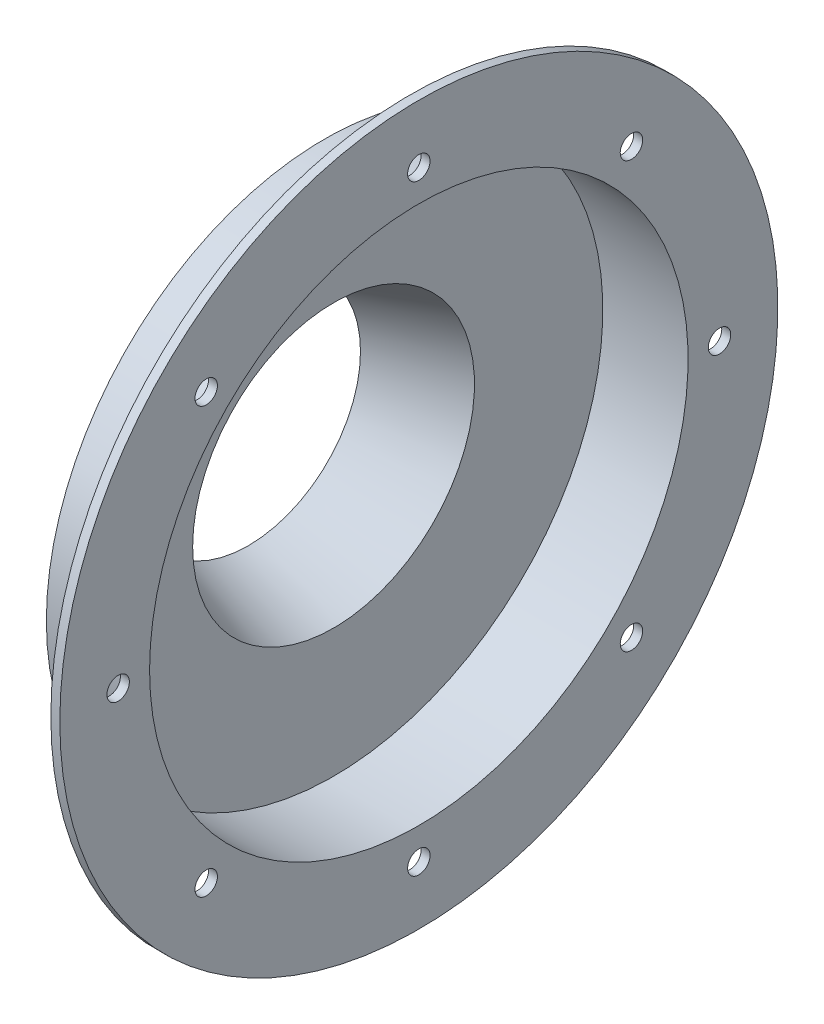
from build123d import *

# Parameters (mm, degrees)
SKETCH2_R          = 3.175
CUT_EXTRUDE1_DEPTH = 2.54
CIRPATTERN1_COUNT  = 8


with BuildPart() as part:
    # Sketch1 → Revolve1 (revolve)
    with BuildSketch(Plane.XY):
        Polygon((0, 31.75), (24.13, 39.878), (24.13, 76.2), (48.26, 76.2), (48.26, 101.6), (45.72, 101.6), (45.72, 78.74), (21.59, 78.74), (21.59, 41.702647785), (-0.810815928, 34.157109788), align=None)
    revolve(axis=Axis((0, 0, 0), (1, 0, 0)))

    # Sketch2 → Cut-Extrude1 (cut)
    with BuildSketch(Plane.ZY.offset(-45.72)):
        with Locations((0, 85.09)):
            Circle(SKETCH2_R)
    cut_extrude1 = extrude(amount=-CUT_EXTRUDE1_DEPTH, mode=Mode.SUBTRACT)

    # CirPattern1: Cut-Extrude1 ×8 about axis
    cirpattern1_axis = Axis((0, 0, 0), (1, 0, 0))
    for i in range(1, CIRPATTERN1_COUNT):
        add(cut_extrude1.rotate(cirpattern1_axis, i * 360 / CIRPATTERN1_COUNT), mode=Mode.SUBTRACT)


solid = part.part
